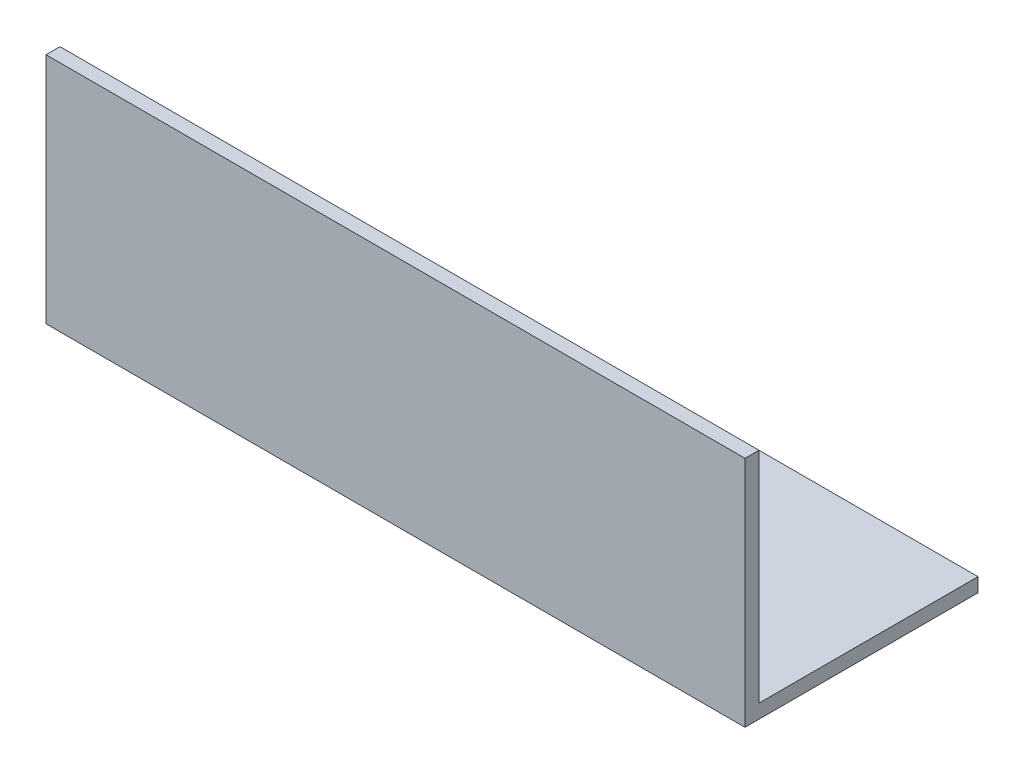
from build123d import *

# Parameters (mm, degrees)
EXTRUDE_THIN1_DEPTH = 76.2


with BuildPart() as part:
    # Sketch1 → Extrude-Thin1 (new body)
    with BuildSketch(Plane(origin=(0, 0, 0), x_dir=(0, 0, -1), z_dir=(1, 0, 0))):
        Polygon((0, 25.4), (0, 0), (25.4, 0), (25.4, 1.524), (1.524, 1.524), (1.524, 25.4), align=None)
    extrude(amount=EXTRUDE_THIN1_DEPTH)


solid = part.part
